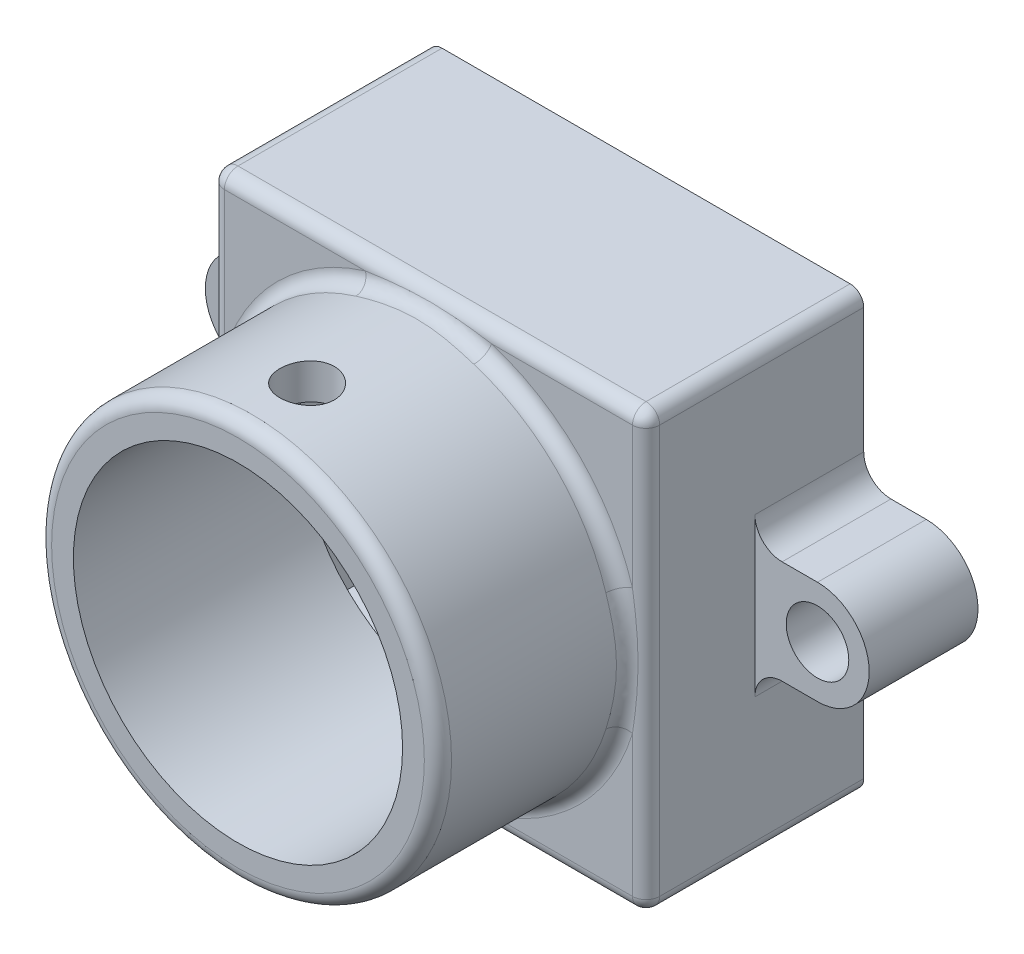
from build123d import *

# Parameters (mm, degrees)
SKETCH1_W          = 16
SKETCH1_H          = 16
EXTRUDE1_DEPTH     = 8
SKETCH2_R          = 7.35
EXTRUDE2_DEPTH     = 7
SHELL1_T           = -1.3
SKETCH6_R          = 1
CUT_EXTRUDE1_DEPTH = 19.788294228
SKETCH4_R          = 1.15
EXTRUDE3_DEPTH     = 4
FILLET1_R          = 0.5
FILLET2_R          = 0.5
FILLET3_R          = 1


with BuildPart() as part:
    # Sketch1 → Extrude1 (new body)
    with BuildSketch(Plane.XY):
        Rectangle(SKETCH1_W, SKETCH1_H)
    extrude(amount=EXTRUDE1_DEPTH)

    # Sketch2 → Extrude2 (add)
    with BuildSketch(Plane.XY.offset(8)):
        Circle(SKETCH2_R)
    extrude(amount=EXTRUDE2_DEPTH)

    # Shell1
    shell1_openings = [part.faces().sort_by_distance(p)[0] for p in [
        (0, 0, 15),
        (0, 0, 0),
    ]]
    offset(amount=SHELL1_T, openings=shell1_openings, kind=Kind.INTERSECTION)

    # Sketch6 → Cut-Extrude1 (cut, through all)
    with BuildSketch(Plane(origin=(0, 0, 0), x_dir=(1, 0, 0), z_dir=(0, 1, 0))):
        with Locations(Location((0, -12.46, 0), (0, 0, 90))):
            Circle(SKETCH6_R)
    extrude(amount=CUT_EXTRUDE1_DEPTH, mode=Mode.SUBTRACT)

    # Sketch4 → Extrude3 (add)
    with BuildSketch(Plane.XY):
        with BuildLine():
            Line((-8, 1.9), (-10.3, 1.9))
            ThreePointArc((-10.3, 1.9), (-12.2, 0), (-10.3, -1.9))
            Line((-10.3, -1.9), (-8, -1.9))
            Line((-8, -1.9), (-8, 1.9))
        make_face()
        with Locations((-10.3, 0)):
            Circle(SKETCH4_R, mode=Mode.SUBTRACT)
        with BuildLine():
            Line((8, 1.9), (8, -1.9))
            Line((8, -1.9), (10.3, -1.9))
            ThreePointArc((10.3, -1.9), (12.2, 0), (10.3, 1.9))
            Line((10.3, 1.9), (8, 1.9))
        make_face()
        with Locations((10.3, 0)):
            Circle(SKETCH4_R, mode=Mode.SUBTRACT)
    extrude(amount=EXTRUDE3_DEPTH)

    # Fillet1
    fillet1_edges = [part.edges().sort_by_distance(p)[0] for p in [
        (-8, 8, 4),
        (-8, -8, 4),
        (8, -8, 4),
        (8, 8, 4),
        (0, -8, 8),
        (-8, 0, 8),
        (0, 8, 8),
        (8, 0, 8),
    ]]
    fillet(fillet1_edges, radius=FILLET1_R)

    # Fillet2
    fillet2_edges = [part.edges().sort_by_distance(p)[0] for p in [
        (-7.35, 0, 8),
        (-7.35, 0, 15),
    ]]
    fillet(fillet2_edges, radius=FILLET2_R)

    # Fillet3
    fillet3_edges = [part.edges().sort_by_distance(p)[0] for p in [
        (8, 1.9, 2),
        (8, -1.9, 2),
        (-8, -1.9, 2),
        (-8, 1.9, 2),
    ]]
    fillet(fillet3_edges, radius=FILLET3_R)


solid = part.part
